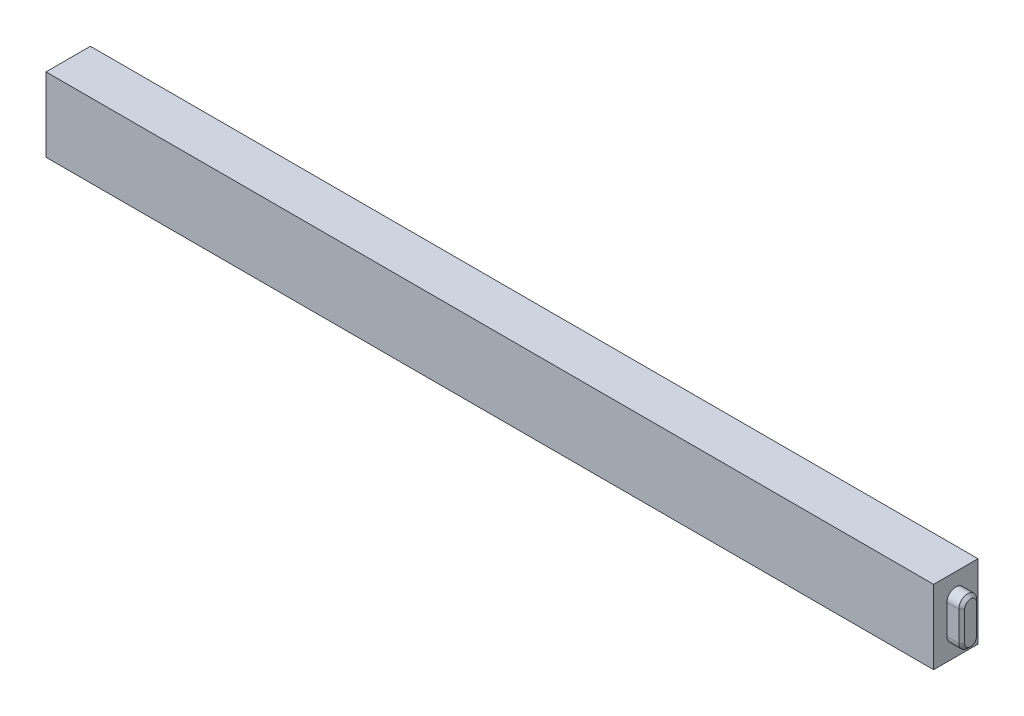
from build123d import *

# Parameters (mm, degrees)
ESQUISSE1_W        = 600
ESQUISSE1_H        = 50
BOSS_EXTRU_1_DEPTH = 30
BOSS_EXTRU_2_DEPTH = 10
CHANFREIN1_SIZE    = 2
BOSS_EXTRU_3_DEPTH = 10
CHANFREIN2_SIZE    = 2


with BuildPart() as part:
    # Esquisse1 → Boss.-Extru.1 (new body)
    with BuildSketch(Plane.XY):
        Rectangle(ESQUISSE1_W, ESQUISSE1_H)
    extrude(amount=BOSS_EXTRU_1_DEPTH)

    # Esquisse2 → Boss.-Extru.2 (add)
    with BuildSketch(Plane(origin=(300, 0, 0), x_dir=(0, 0, -1), z_dir=(1, 0, 0))):
        with BuildLine():
            Line((-9, 10), (-9, -10))
            ThreePointArc((-9, -10), (-15, -16), (-21, -10))
            Line((-21, -10), (-21, 10))
            ThreePointArc((-21, 10), (-15, 16), (-9, 10))
        make_face()
    extrude(amount=BOSS_EXTRU_2_DEPTH)

    # Chanfrein1
    chanfrein1_edges = [part.edges().sort_by_distance(p)[0] for p in [
        (310, 16, 15),
        (310, 0, 21),
        (310, -16, 15),
        (310, 0, 9),
    ]]
    chamfer(chanfrein1_edges, length=CHANFREIN1_SIZE)

    # Esquisse3 → Boss.-Extru.3 (add)
    with BuildSketch(Plane.ZY.offset(300)):
        with BuildLine():
            Line((21, 10), (21, -10))
            ThreePointArc((21, -10), (15, -16), (9, -10))
            Line((9, -10), (9, 10))
            ThreePointArc((9, 10), (15, 16), (21, 10))
        make_face()
    extrude(amount=BOSS_EXTRU_3_DEPTH)

    # Chanfrein2
    chanfrein2_edges = [part.edges().sort_by_distance(p)[0] for p in [
        (-310, 0, 21),
        (-310, 16, 15),
        (-310, 0, 9),
        (-310, -16, 15),
    ]]
    chamfer(chanfrein2_edges, length=CHANFREIN2_SIZE)


solid = part.part
